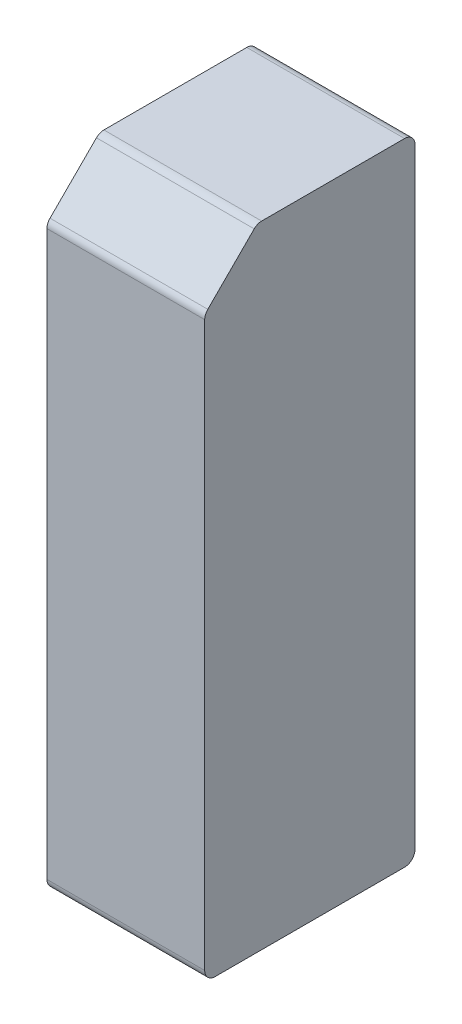
from build123d import *

# Parameters (mm, degrees)
BOSS_EXTRUDE1_DEPTH = 9.525
FILLET1_R           = 0.635


with BuildPart() as part:
    # Sketch1 → Boss-Extrude1 (new body)
    with BuildSketch(Plane(origin=(0, 0, 0), x_dir=(0, 0, -1), z_dir=(1, 0, 0))):
        Polygon((-6.35, 17.4625), (-3.175, 20.6375), (6.35, 20.6375), (6.35, 17.4625), (6.35, -17.4625), (-6.35, -17.4625), align=None)
    extrude(amount=BOSS_EXTRUDE1_DEPTH)

    # Fillet1
    fillet1_edges = [part.edges().sort_by_distance(p)[0] for p in [
        (4.7625, -17.4625, -6.35),
        (4.7625, -17.4625, 6.35),
        (4.7625, 17.4625, 6.35),
        (4.7625, 20.6375, 3.175),
        (4.7625, 20.6375, -6.35),
    ]]
    fillet(fillet1_edges, radius=FILLET1_R)


solid = part.part
